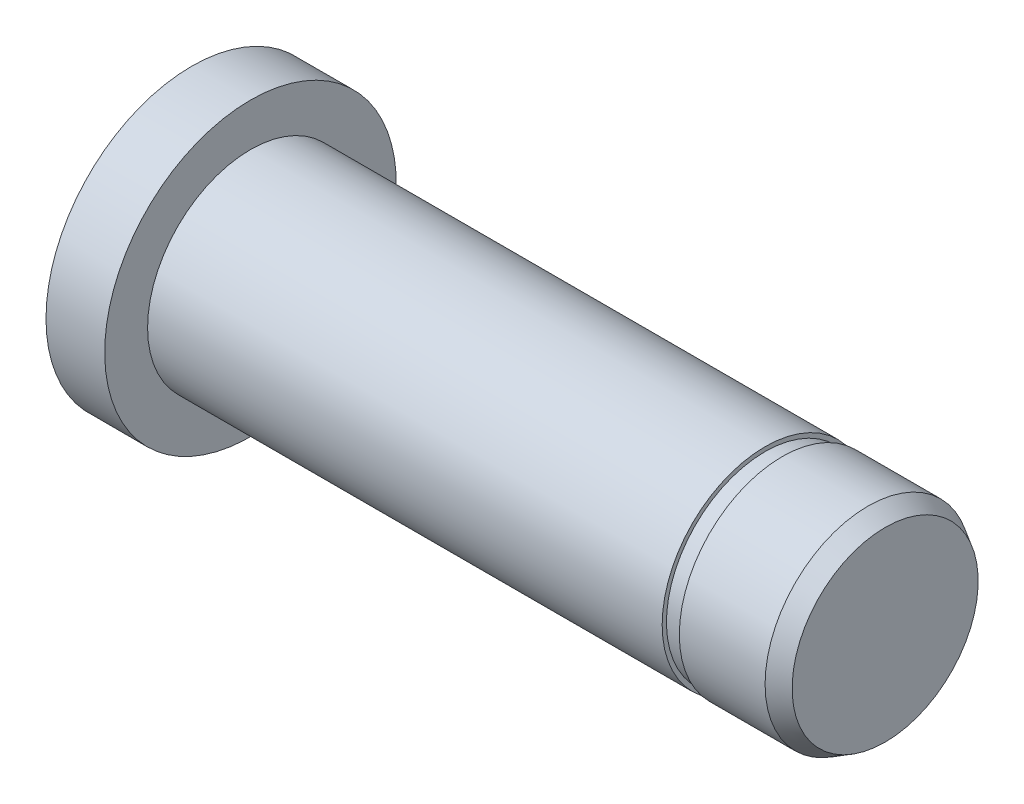
from build123d import *

# Parameters (mm, degrees)
SFAZOWANIE1_SIZE           = 1
SFAZOWANIE1_SIZE2          = 0.577350269
SFAZOWANIE1_PART_2_SIZE    = 1
SFAZOWANIE1_PART_2_SIZE2   = 0.577350269
WYTNIJ_WYCI_GNI_CIE1_START = -6
SZKIC2_R                   = 6
SZKIC2_R_2                 = 5.75
WYTNIJ_WYCI_GNI_CIE1_DEPTH = 1


with BuildPart() as part:
    # Szkic1 → Obrót1 (revolve)
    with BuildSketch(Plane.XY):
        Polygon((0, 0), (0, 8.5), (4, 8.5), (4, 6), (41, 6), (41, 0), align=None)
    revolve(axis=Axis((41, 0, 0), (-1, 0, 0)))

    # Sfazowanie1
    sfazowanie1_edges = [part.edges().sort_by_distance(p)[0] for p in [
        (41, -6, 0),
    ]]
    sfazowanie1_side = [part.faces().sort_by_distance(p)[0] for p in [
        (22.5, -6, 0),
    ]]
    chamfer(sfazowanie1_edges, length=SFAZOWANIE1_SIZE, length2=SFAZOWANIE1_SIZE2, reference=sfazowanie1_side[0])

    # Sfazowanie1 part 2
    sfazowanie1_part_2_edges = [part.edges().sort_by_distance(p)[0] for p in [
        (0, -8.5, 0),
    ]]
    sfazowanie1_part_2_side = [part.faces().sort_by_distance(p)[0] for p in [
        (0, 0, 0),
    ]]
    chamfer(sfazowanie1_part_2_edges, length=SFAZOWANIE1_PART_2_SIZE, length2=SFAZOWANIE1_PART_2_SIZE2, reference=sfazowanie1_part_2_side[0])

    # Szkic2 → Wytnij-wyciągnięcie1 (cut)
    with BuildSketch(Plane(origin=(41, 0, 0), x_dir=(0, 0, -1), z_dir=(1, 0, 0)).offset(WYTNIJ_WYCI_GNI_CIE1_START)):
        Circle(SZKIC2_R)
        Circle(SZKIC2_R_2, mode=Mode.SUBTRACT)
    extrude(amount=-WYTNIJ_WYCI_GNI_CIE1_DEPTH, mode=Mode.SUBTRACT)


solid = part.part
